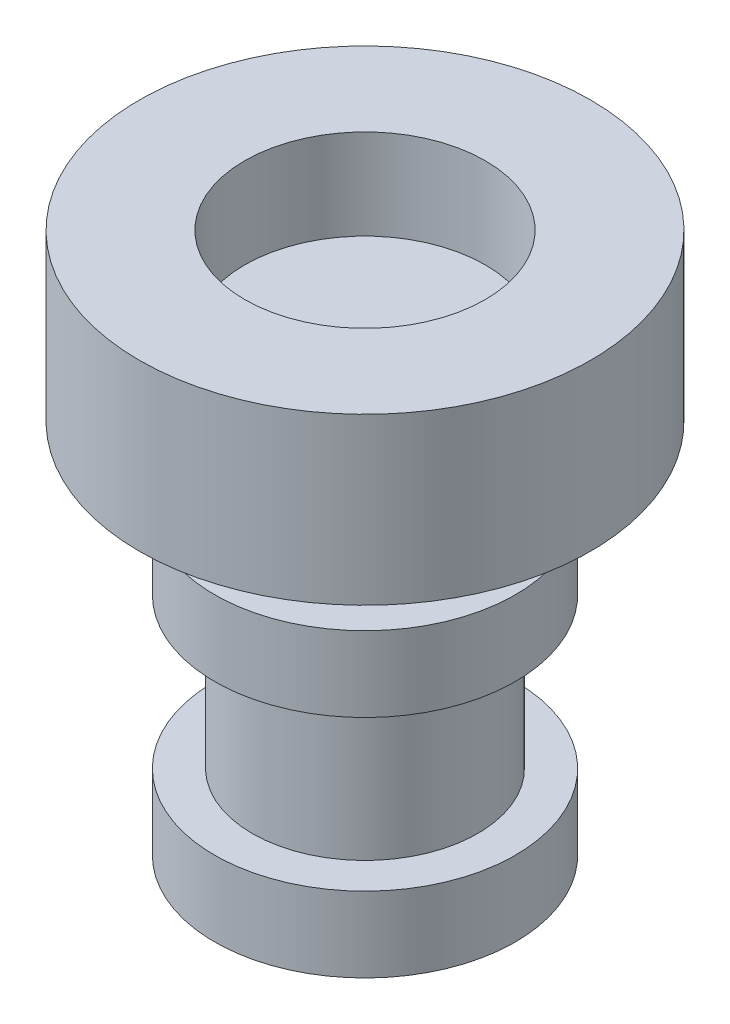
from build123d import *

# Parameters (mm, degrees)
SKETCH1_R           = 3
SKETCH1_R_2         = 1.6
BOSS_EXTRUDE1_DEPTH = 2.2
SKETCH1_3_R         = 1.6
BOSS_EXTRUDE2_DEPTH = 1
SKETCH5_R           = 1.5
BOSS_EXTRUDE3_DEPTH = 1
SKETCH6_R           = 2
BOSS_EXTRUDE4_DEPTH = 1
SKETCH8_R           = 1.5
BOSS_EXTRUDE5_DEPTH = 3
BOSS_EXTRUDE6_START = -1
SKETCH10_R          = 2
BOSS_EXTRUDE6_DEPTH = 1


with BuildPart() as part:
    # Sketch1 → Boss-Extrude1 (new body)
    with BuildSketch(Plane(origin=(0, 0, 0), x_dir=(1, 0, 0), z_dir=(0, 1, 0))):
        with Locations((-0.522013312, 0.511138034)):
            Circle(SKETCH1_R)
        with Locations((-0.522013312, 0.511138034)):
            Circle(SKETCH1_R_2, mode=Mode.SUBTRACT)
    extrude(amount=BOSS_EXTRUDE1_DEPTH)

    # Sketch1_3 → Boss-Extrude2 (add)
    with BuildSketch(Plane(origin=(0, 0, 0), x_dir=(1, 0, 0), z_dir=(0, 1, 0))):
        with Locations((-0.522013312, 0.511138034)):
            Circle(SKETCH1_3_R)
    extrude(amount=BOSS_EXTRUDE2_DEPTH)

    # Sketch5 → Boss-Extrude3 (add)
    with BuildSketch(Plane.XZ):
        with Locations((-0.522013312, -0.511138034)):
            Circle(SKETCH5_R)
    extrude(amount=BOSS_EXTRUDE3_DEPTH)

    # Sketch6 → Boss-Extrude4 (add)
    with BuildSketch(Plane.XZ.offset(1)):
        with Locations((-0.522013312, -0.511138034)):
            Circle(SKETCH6_R)
    extrude(amount=BOSS_EXTRUDE4_DEPTH)

    # Sketch8 → Boss-Extrude5 (add)
    with BuildSketch(Plane(origin=(0, -2, 0), x_dir=(-1, 0, 0), z_dir=(0, -1, 0))):
        with Locations((0.522013312, 0.511138034)):
            Circle(SKETCH8_R)
    extrude(amount=BOSS_EXTRUDE5_DEPTH)

    # Sketch10 → Boss-Extrude6 (add)
    with BuildSketch(Plane.XZ.offset(5).offset(BOSS_EXTRUDE6_START)):
        with Locations((-0.522013312, -0.511138034)):
            Circle(SKETCH10_R)
    extrude(amount=BOSS_EXTRUDE6_DEPTH)


solid = part.part
